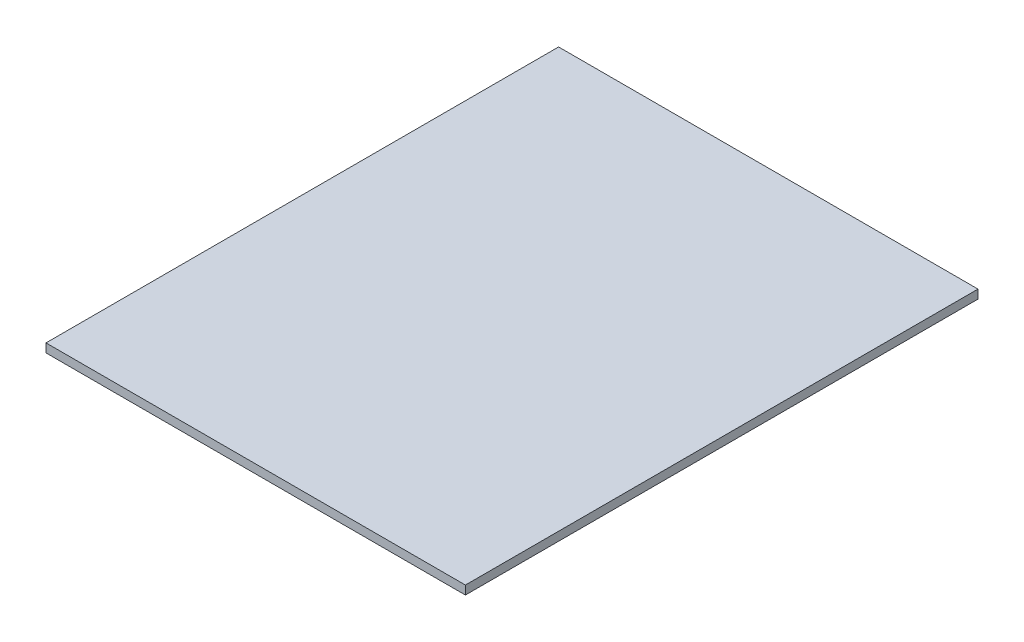
from build123d import *

# Parameters (mm, degrees)
SKETCH1_W           = 135
SKETCH1_H           = 165
BOSS_EXTRUDE1_DEPTH = 2.8


with BuildPart() as part:
    # Sketch1 → Boss-Extrude1 (new body)
    with BuildSketch(Plane(origin=(0, 0, 0), x_dir=(1, 0, 0), z_dir=(0, 1, 0))):
        Rectangle(SKETCH1_W, SKETCH1_H)
    extrude(amount=BOSS_EXTRUDE1_DEPTH)


solid = part.part
